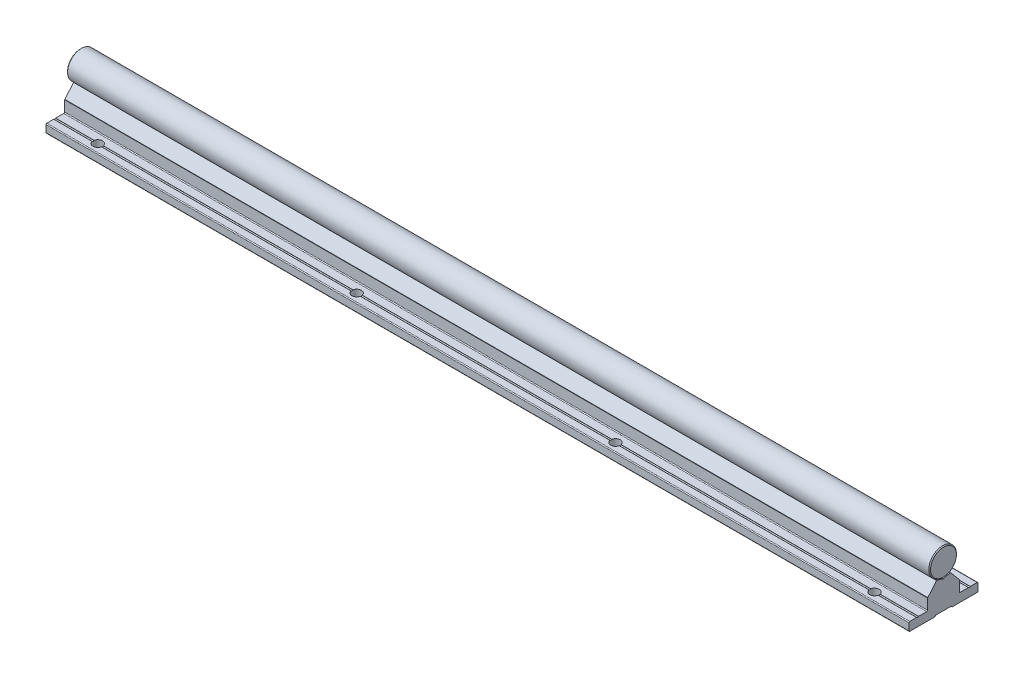
from build123d import *

# Parameters (mm, degrees)
EXTRUDE_3982_DEPTH       = 1500
SKETCH_1_3_R             = 8
EXTRUDE_4111_DEPTH       = 1500
FILLET_4_R               = 0.2
SKETCH_2_R               = 2.75
CUT_EXTRUDE_1_DEPTH      = 6
PATTERN_LINEAR_1_COUNT   = 20
PATTERN_LINEAR_1_PITCH   = 150
PATTERN_LINEAR_2_COUNT   = 20
PATTERN_LINEAR_2_PITCH   = 150
FILLET_1_R               = 0.3
CUT_EXTRUDE_2_DEPTH      = 3
FILLET_2_R               = 0.3
PATTERN_LINEAR_3_COUNT   = 20
PATTERN_LINEAR_3_PITCH   = 150
CHAMFER_1_SIZE           = 0.5
FILLET_3_R               = 0.5
FILLET_5_R               = 0.2
FILLET_6_R               = 0.1
FILLET_7_R               = 0.1
SKETCH_7_W               = 3500
SKETCH_7_H               = 1500
SKETCH_7_W_2             = 500
SKETCH_7_H_2             = 1000
CUT_EXTRUDE_3_DEPTH      = 9.0000001
CUT_EXTRUDE_3_DEPTH_BACK = 26.0000001
CHAMFER_2_SIZE           = 0.5


with BuildPart() as part:
    # Sketch 1 → Extrude 3982 (new body, symmetric)
    with BuildSketch(Plane(origin=(0, 0, 0), x_dir=(0, 0, -1), z_dir=(1, 0, 0))):
        Polygon((-20, -25), (-4.75, -25), (-4.75, -24.4), (4.75, -24.4), (4.75, -25), (20, -25), (20, -20), (15.5, -20), (15, -20.5), (14.5, -20), (9.25, -20), (9.25, -13.3), (9.110116754, -13.3), (4, -7.21), (3.8, -7.21), (2.309327639, -7.659439004), (0, -8.355703281), (-2.309327657, -7.659438999), (-3.8, -7.21), (-4, -7.21), (-9.110116754, -13.3), (-9.25, -13.3), (-9.25, -20), (-14.5, -20), (-15, -20.5), (-15.5, -20), (-20, -20), align=None)
    extrude(amount=EXTRUDE_3982_DEPTH, both=True)

    # Fillet 4
    fillet_4_edges = [part.edges().sort_by_distance(p)[0] for p in [
        (0, -20, -15.5),
        (0, -24.4, -4.75),
        (0, -24.4, 4.75),
        (0, -20, 15.5),
        (0, -20, 14.5),
        (0, -8.355703281, 0),
        (0, -20, -14.5),
    ]]
    fillet(fillet_4_edges, radius=FILLET_4_R)

    # Sketch 2 → Cut-Extrude 1 (cut, through all)
    with BuildSketch(Plane(origin=(0, -20, 0), x_dir=(1, 0, 0), z_dir=(0, 1, 0))):
        with Locations((-1425, -15)):
            Circle(SKETCH_2_R)
        with Locations((-1425, 15)):
            Circle(SKETCH_2_R)
        with Locations((-1275, -15)):
            Circle(SKETCH_2_R)
        with Locations((-1275, 15)):
            Circle(SKETCH_2_R)
        with Locations((-1125, -15)):
            Circle(SKETCH_2_R)
        with Locations((-1125, 15)):
            Circle(SKETCH_2_R)
        with Locations((-975, -15)):
            Circle(SKETCH_2_R)
        with Locations((-975, 15)):
            Circle(SKETCH_2_R)
        with Locations((-825, -15)):
            Circle(SKETCH_2_R)
        with Locations((-825, 15)):
            Circle(SKETCH_2_R)
        with Locations((-675, -15)):
            Circle(SKETCH_2_R)
        with Locations((-675, 15)):
            Circle(SKETCH_2_R)
        with Locations((-525, -15)):
            Circle(SKETCH_2_R)
        with Locations((-525, 15)):
            Circle(SKETCH_2_R)
        with Locations((-375, -15)):
            Circle(SKETCH_2_R)
        with Locations((-375, 15)):
            Circle(SKETCH_2_R)
        with Locations((-225, -15)):
            Circle(SKETCH_2_R)
        with Locations((-225, 15)):
            Circle(SKETCH_2_R)
        with Locations((-75, -15)):
            Circle(SKETCH_2_R)
        with Locations((-75, 15)):
            Circle(SKETCH_2_R)
        with Locations((75, -15)):
            Circle(SKETCH_2_R)
        with Locations((75, 15)):
            Circle(SKETCH_2_R)
        with Locations((225, -15)):
            Circle(SKETCH_2_R)
        with Locations((225, 15)):
            Circle(SKETCH_2_R)
        with Locations((375, -15)):
            Circle(SKETCH_2_R)
        with Locations((375, 15)):
            Circle(SKETCH_2_R)
        with Locations((525, -15)):
            Circle(SKETCH_2_R)
        with Locations((525, 15)):
            Circle(SKETCH_2_R)
        with Locations((675, -15)):
            Circle(SKETCH_2_R)
        with Locations((675, 15)):
            Circle(SKETCH_2_R)
        with Locations((825, -15)):
            Circle(SKETCH_2_R)
        with Locations((825, 15)):
            Circle(SKETCH_2_R)
        with Locations((975, -15)):
            Circle(SKETCH_2_R)
        with Locations((975, 15)):
            Circle(SKETCH_2_R)
        with Locations((1125, -15)):
            Circle(SKETCH_2_R)
        with Locations((1125, 15)):
            Circle(SKETCH_2_R)
        with Locations((1275, -15)):
            Circle(SKETCH_2_R)
        with Locations((1275, 15)):
            Circle(SKETCH_2_R)
        with Locations((1425, -15)):
            Circle(SKETCH_2_R)
        with Locations((1425, 15)):
            Circle(SKETCH_2_R)
    extrude(amount=-CUT_EXTRUDE_1_DEPTH, mode=Mode.SUBTRACT)

    # Sketch 3 → Cut-Revolve 1 (revolve, cut)
    with BuildSketch(Plane.XY):
        Polygon((-1425, 0), (-1427.2, -1.270170592), (-1427.2, -7.5), (-1427.75, -7.5), (-1427.75, -19), (-1429.75, -19), (-1429.75, -24.4), (-1425, -24.4), align=None)
    cut_revolve_1 = revolve(axis=Axis((-1425, 56.434869358, 0), (0, -1, 0)), mode=Mode.SUBTRACT)

    # Pattern Linear 1: Cut-Revolve 1 ×20
    with Locations(*[(i * PATTERN_LINEAR_1_PITCH, 0, 0) for i in range(1, PATTERN_LINEAR_1_COUNT)]):
        add(cut_revolve_1, mode=Mode.SUBTRACT)

    # Fillet 3
    fillet_3_edges = [part.edges().sort_by_distance(p)[0] for p in [
        (0, -20, -9.25),
        (0, -20, -20),
        (0, -25, -20),
        (0, -25, -4.75),
        (0, -25, 4.75),
        (0, -20, 9.25),
        (0, -25, 20),
        (0, -20, 20),
    ]]
    fillet(fillet_3_edges, radius=FILLET_3_R)

    # Fillet 5
    fillet_5_edges = [part.edges().sort_by_distance(p)[0] for p in [
        (0, -7.21, 4),
        (0, -7.21, 3.8),
        (0, -7.21, -3.8),
        (0, -7.21, -4),
    ]]
    fillet(fillet_5_edges, radius=FILLET_5_R)

    # Fillet 6
    fillet_6_edges = [part.edges().sort_by_distance(p)[0] for p in [
        (0, -13.3, 9.25),
        (0, -13.3, -9.25),
    ]]
    fillet(fillet_6_edges, radius=FILLET_6_R)

    # Fillet 7
    fillet_7_edges = [part.edges().sort_by_distance(p)[0] for p in [
        (0, -13.3, 9.110116754),
        (0, -13.3, -9.110116754),
    ]]
    fillet(fillet_7_edges, radius=FILLET_7_R)


with BuildPart() as body_2:
    # Sketch 1_3 → Extrude 4111 (new body, symmetric)
    with BuildSketch(Plane(origin=(0, 0, 0), x_dir=(0, 0, -1), z_dir=(1, 0, 0))):
        Circle(SKETCH_1_3_R)
    extrude(amount=EXTRUDE_4111_DEPTH, both=True)

    # Sketch 4 → Cut-Revolve 2 (revolve, cut)
    with BuildSketch(Plane.XY):
        Polygon((-1425, -10), (-1427.2, -10), (-1427.2, -1.270170592), (-1425, 0), align=None)
    cut_revolve_2 = revolve(axis=Axis((-1425, 39.840222878, 0), (0, -1, 0)), mode=Mode.SUBTRACT)

    # Pattern Linear 2: Cut-Revolve 2 ×20
    with Locations(*[(i * PATTERN_LINEAR_2_PITCH, 0, 0) for i in range(1, PATTERN_LINEAR_2_COUNT)]):
        add(cut_revolve_2, mode=Mode.SUBTRACT)

    # Chamfer 1
    chamfer_1_edges = [body_2.edges().sort_by_distance(p)[0] for p in [
        (-1500, 0, 8),
        (1500, 0, 8),
    ]]
    chamfer(chamfer_1_edges, length=CHAMFER_1_SIZE)


with BuildPart() as body_3:
    # Sketch 5 → Revolve 1 (revolve)
    with BuildSketch(Plane.XY):
        Polygon((-1425, -24), (-1429.5, -24), (-1429.5, -19), (-1427.5, -19), (-1427.5, -2.461880215), (-1426.7, -2), (-1425, -2), align=None)
    revolve(axis=Axis((-1425, 35.529626596, 0), (0, -1, 0)))

    # Fillet 1
    fillet_1_edges = [body_3.edges().sort_by_distance(p)[0] for p in [
        (-1420.5, -19, 0),
    ]]
    fillet(fillet_1_edges, radius=FILLET_1_R)

    # Sketch 6 → Cut-Extrude 2 (cut)
    with BuildSketch(Plane.XZ.offset(24)):
        Polygon((-1423.25, -1.010362971), (-1423.25, 1.010362971), (-1425, 2.020725942), (-1426.75, 1.010362971), (-1426.75, -1.010362971), (-1425, -2.020725942), align=None)
    extrude(amount=-CUT_EXTRUDE_2_DEPTH, mode=Mode.SUBTRACT)

    # Fillet 2
    fillet_2_edges = [body_3.edges().sort_by_distance(p)[0] for p in [
        (-1424.125, -24, -1.515544457),
        (-1423.25, -24, 0),
        (-1424.125, -24, 1.515544457),
        (-1425.875, -24, 1.515544457),
        (-1426.75, -24, 0),
        (-1425.875, -24, -1.515544457),
        (-1420.5, -24, 0),
    ]]
    fillet(fillet_2_edges, radius=FILLET_2_R)


with BuildPart() as pattern_linear_3_1:
    # Pattern Linear 3: pattern copy
    add(body_3.part.moved(Location(Vector(1, 0, 0) * (1 * PATTERN_LINEAR_3_PITCH))))


with BuildPart() as pattern_linear_3_2:
    # Pattern Linear 3: pattern copy
    add(body_3.part.moved(Location(Vector(1, 0, 0) * (2 * PATTERN_LINEAR_3_PITCH))))


with BuildPart() as pattern_linear_3_3:
    # Pattern Linear 3: pattern copy
    add(body_3.part.moved(Location(Vector(1, 0, 0) * (3 * PATTERN_LINEAR_3_PITCH))))


with BuildPart() as pattern_linear_3_4:
    # Pattern Linear 3: pattern copy
    add(body_3.part.moved(Location(Vector(1, 0, 0) * (4 * PATTERN_LINEAR_3_PITCH))))


with BuildPart() as pattern_linear_3_5:
    # Pattern Linear 3: pattern copy
    add(body_3.part.moved(Location(Vector(1, 0, 0) * (5 * PATTERN_LINEAR_3_PITCH))))


with BuildPart() as pattern_linear_3_6:
    # Pattern Linear 3: pattern copy
    add(body_3.part.moved(Location(Vector(1, 0, 0) * (6 * PATTERN_LINEAR_3_PITCH))))


with BuildPart() as pattern_linear_3_7:
    # Pattern Linear 3: pattern copy
    add(body_3.part.moved(Location(Vector(1, 0, 0) * (7 * PATTERN_LINEAR_3_PITCH))))


with BuildPart() as pattern_linear_3_8:
    # Pattern Linear 3: pattern copy
    add(body_3.part.moved(Location(Vector(1, 0, 0) * (8 * PATTERN_LINEAR_3_PITCH))))


with BuildPart() as pattern_linear_3_9:
    # Pattern Linear 3: pattern copy
    add(body_3.part.moved(Location(Vector(1, 0, 0) * (9 * PATTERN_LINEAR_3_PITCH))))


with BuildPart() as pattern_linear_3_10:
    # Pattern Linear 3: pattern copy
    add(body_3.part.moved(Location(Vector(1, 0, 0) * (10 * PATTERN_LINEAR_3_PITCH))))


with BuildPart() as pattern_linear_3_11:
    # Pattern Linear 3: pattern copy
    add(body_3.part.moved(Location(Vector(1, 0, 0) * (11 * PATTERN_LINEAR_3_PITCH))))


with BuildPart() as pattern_linear_3_12:
    # Pattern Linear 3: pattern copy
    add(body_3.part.moved(Location(Vector(1, 0, 0) * (12 * PATTERN_LINEAR_3_PITCH))))


with BuildPart() as pattern_linear_3_13:
    # Pattern Linear 3: pattern copy
    add(body_3.part.moved(Location(Vector(1, 0, 0) * (13 * PATTERN_LINEAR_3_PITCH))))


with BuildPart() as pattern_linear_3_14:
    # Pattern Linear 3: pattern copy
    add(body_3.part.moved(Location(Vector(1, 0, 0) * (14 * PATTERN_LINEAR_3_PITCH))))


with BuildPart() as pattern_linear_3_15:
    # Pattern Linear 3: pattern copy
    add(body_3.part.moved(Location(Vector(1, 0, 0) * (15 * PATTERN_LINEAR_3_PITCH))))


with BuildPart() as pattern_linear_3_16:
    # Pattern Linear 3: pattern copy
    add(body_3.part.moved(Location(Vector(1, 0, 0) * (16 * PATTERN_LINEAR_3_PITCH))))


with BuildPart() as pattern_linear_3_17:
    # Pattern Linear 3: pattern copy
    add(body_3.part.moved(Location(Vector(1, 0, 0) * (17 * PATTERN_LINEAR_3_PITCH))))


with BuildPart() as pattern_linear_3_18:
    # Pattern Linear 3: pattern copy
    add(body_3.part.moved(Location(Vector(1, 0, 0) * (18 * PATTERN_LINEAR_3_PITCH))))


with BuildPart() as pattern_linear_3_19:
    # Pattern Linear 3: pattern copy
    add(body_3.part.moved(Location(Vector(1, 0, 0) * (19 * PATTERN_LINEAR_3_PITCH))))


with BuildPart() as cut_extrude_3_tool:
    # Sketch 7 → Cut-Extrude 3 (new body, two sides)
    with BuildSketch(Plane(origin=(0, 0, 0), x_dir=(1, 0, 0), z_dir=(0, 1, 0))) as cut_extrude_3_sk:
        Rectangle(SKETCH_7_W, SKETCH_7_H)
        Rectangle(SKETCH_7_W_2, SKETCH_7_H_2, mode=Mode.SUBTRACT)
    extrude(amount=CUT_EXTRUDE_3_DEPTH)
    extrude(cut_extrude_3_sk.sketch, amount=-CUT_EXTRUDE_3_DEPTH_BACK)


with BuildPart() as part_1:
    add(part.part)

    # Cut-Extrude 3: cut by cut_extrude_3_tool
    add(cut_extrude_3_tool.part, mode=Mode.SUBTRACT)


with BuildPart() as body_2_1:
    add(body_2.part)

    # Cut-Extrude 3: cut by cut_extrude_3_tool
    add(cut_extrude_3_tool.part, mode=Mode.SUBTRACT)

    # Chamfer 2
    chamfer_2_edges = [body_2_1.edges().sort_by_distance(p)[0] for p in [
        (-250, 0, 8),
        (250, 0, 8),
    ]]
    chamfer(chamfer_2_edges, length=CHAMFER_2_SIZE)


with BuildPart() as body_3_1:
    add(body_3.part)

    # Cut-Extrude 3: cut by cut_extrude_3_tool
    add(cut_extrude_3_tool.part, mode=Mode.SUBTRACT)


with BuildPart() as pattern_linear_3_1_1:
    add(pattern_linear_3_1.part)

    # Cut-Extrude 3: cut by cut_extrude_3_tool
    add(cut_extrude_3_tool.part, mode=Mode.SUBTRACT)


with BuildPart() as pattern_linear_3_2_1:
    add(pattern_linear_3_2.part)

    # Cut-Extrude 3: cut by cut_extrude_3_tool
    add(cut_extrude_3_tool.part, mode=Mode.SUBTRACT)


with BuildPart() as pattern_linear_3_3_1:
    add(pattern_linear_3_3.part)

    # Cut-Extrude 3: cut by cut_extrude_3_tool
    add(cut_extrude_3_tool.part, mode=Mode.SUBTRACT)


with BuildPart() as pattern_linear_3_4_1:
    add(pattern_linear_3_4.part)

    # Cut-Extrude 3: cut by cut_extrude_3_tool
    add(cut_extrude_3_tool.part, mode=Mode.SUBTRACT)


with BuildPart() as pattern_linear_3_5_1:
    add(pattern_linear_3_5.part)

    # Cut-Extrude 3: cut by cut_extrude_3_tool
    add(cut_extrude_3_tool.part, mode=Mode.SUBTRACT)


with BuildPart() as pattern_linear_3_6_1:
    add(pattern_linear_3_6.part)

    # Cut-Extrude 3: cut by cut_extrude_3_tool
    add(cut_extrude_3_tool.part, mode=Mode.SUBTRACT)


with BuildPart() as pattern_linear_3_7_1:
    add(pattern_linear_3_7.part)

    # Cut-Extrude 3: cut by cut_extrude_3_tool
    add(cut_extrude_3_tool.part, mode=Mode.SUBTRACT)


with BuildPart() as pattern_linear_3_12_1:
    add(pattern_linear_3_12.part)

    # Cut-Extrude 3: cut by cut_extrude_3_tool
    add(cut_extrude_3_tool.part, mode=Mode.SUBTRACT)


with BuildPart() as pattern_linear_3_13_1:
    add(pattern_linear_3_13.part)

    # Cut-Extrude 3: cut by cut_extrude_3_tool
    add(cut_extrude_3_tool.part, mode=Mode.SUBTRACT)


with BuildPart() as pattern_linear_3_14_1:
    add(pattern_linear_3_14.part)

    # Cut-Extrude 3: cut by cut_extrude_3_tool
    add(cut_extrude_3_tool.part, mode=Mode.SUBTRACT)


with BuildPart() as pattern_linear_3_15_1:
    add(pattern_linear_3_15.part)

    # Cut-Extrude 3: cut by cut_extrude_3_tool
    add(cut_extrude_3_tool.part, mode=Mode.SUBTRACT)


with BuildPart() as pattern_linear_3_16_1:
    add(pattern_linear_3_16.part)

    # Cut-Extrude 3: cut by cut_extrude_3_tool
    add(cut_extrude_3_tool.part, mode=Mode.SUBTRACT)


with BuildPart() as pattern_linear_3_17_1:
    add(pattern_linear_3_17.part)

    # Cut-Extrude 3: cut by cut_extrude_3_tool
    add(cut_extrude_3_tool.part, mode=Mode.SUBTRACT)


with BuildPart() as pattern_linear_3_18_1:
    add(pattern_linear_3_18.part)

    # Cut-Extrude 3: cut by cut_extrude_3_tool
    add(cut_extrude_3_tool.part, mode=Mode.SUBTRACT)


with BuildPart() as pattern_linear_3_19_1:
    add(pattern_linear_3_19.part)

    # Cut-Extrude 3: cut by cut_extrude_3_tool
    add(cut_extrude_3_tool.part, mode=Mode.SUBTRACT)


solid = Compound([pattern_linear_3_8.part, pattern_linear_3_9.part, pattern_linear_3_10.part, pattern_linear_3_11.part, part_1.part, body_2_1.part])
